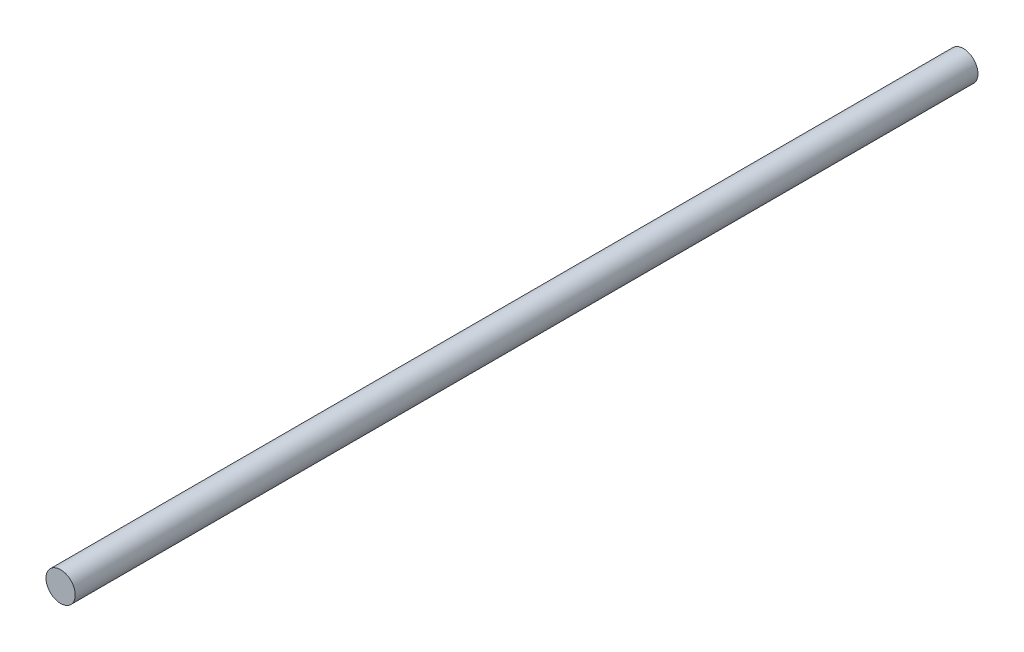
from build123d import *

# Parameters (mm, degrees)
SKETCH1_R           = 3
BOSS_EXTRUDE1_DEPTH = 185


with BuildPart() as part:
    # Sketch1 → Boss-Extrude1 (new body)
    with BuildSketch(Plane.XY):
        Circle(SKETCH1_R)
    extrude(amount=BOSS_EXTRUDE1_DEPTH)


solid = part.part
